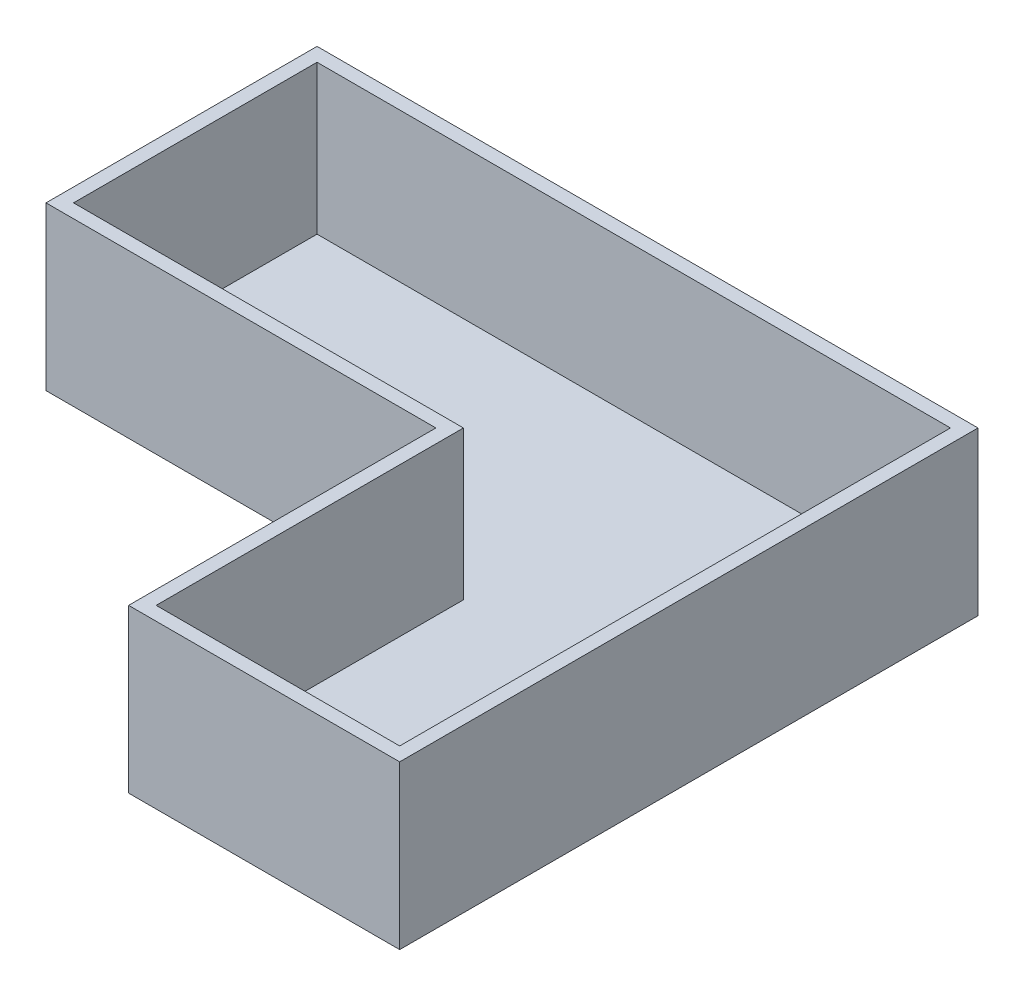
from build123d import *

# Parameters (mm, degrees)
BOSS_EXTRUDE1_DEPTH = 300
CUT_EXTRUDE1_DEPTH  = 274.6


with BuildPart() as part:
    # Sketch1 → Boss-Extrude1 (new body)
    with BuildSketch(Plane(origin=(0, 0, 0), x_dir=(1, 0, 0), z_dir=(0, 1, 0))):
        Polygon((359.6, 1066.8), (-359.6, 1066.8), (-359.6, 566.8), (359.6, 566.8), (359.6, 0), (859.6, 0), (859.6, 1066.8), align=None)
    extrude(amount=BOSS_EXTRUDE1_DEPTH)

    # Sketch2 → Cut-Extrude1 (cut)
    with BuildSketch(Plane(origin=(0, 300, 0), x_dir=(1, 0, 0), z_dir=(0, 1, 0))):
        Polygon((834.2, 25.4), (834.2, 1041.4), (-334.2, 1041.4), (-334.2, 592.2), (385, 592.2), (385, 25.4), align=None)
    extrude(amount=-CUT_EXTRUDE1_DEPTH, mode=Mode.SUBTRACT)


solid = part.part
